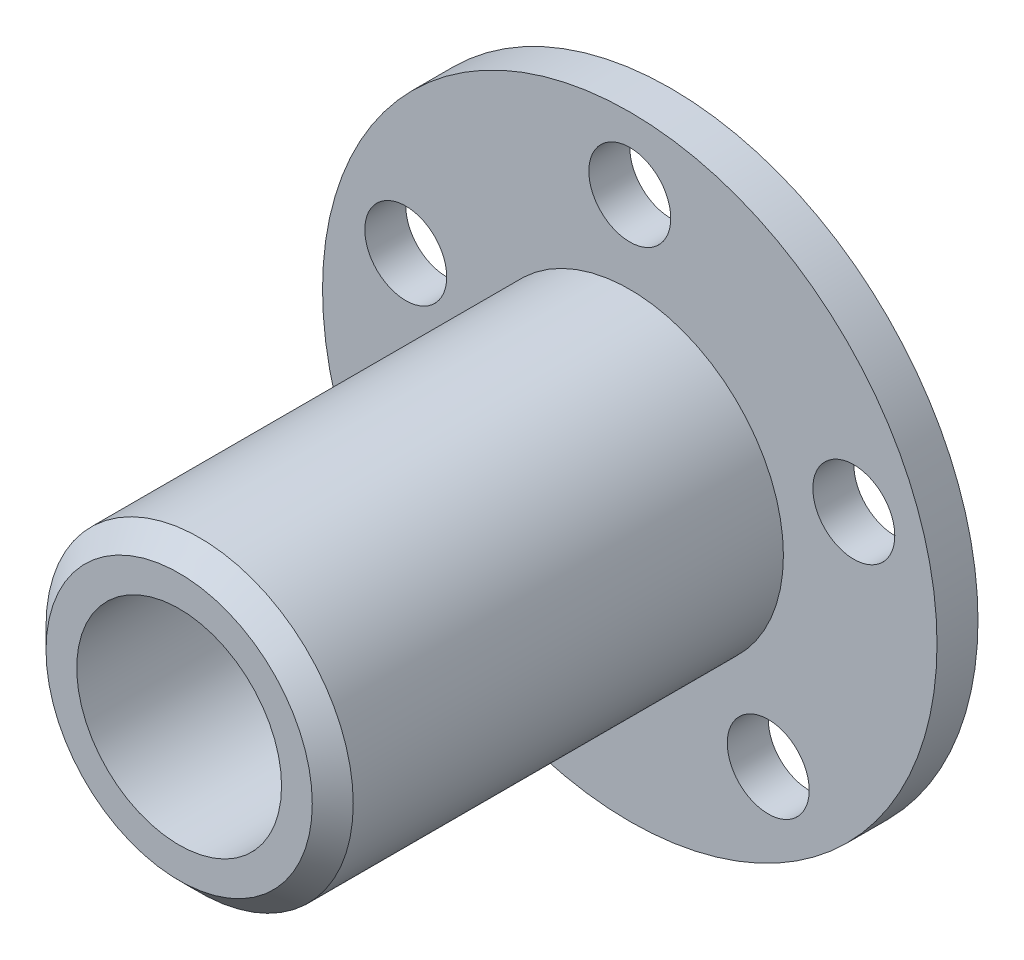
from build123d import *

# Parameters (mm, degrees)
SKETCH1_R           = 15
BOSS_EXTRUDE1_DEPTH = 2
SKETCH2_R           = 7.5
BOSS_EXTRUDE2_DEPTH = 22
SKETCH3_R           = 5
CUT_EXTRUDE1_DEPTH  = 25
SKETCH4_R           = 2
CUT_EXTRUDE2_DEPTH  = 3
CHAMFER1_SIZE       = 1
CHAMFER2_SIZE       = 1


with BuildPart() as part:
    # Sketch1 → Boss-Extrude1 (new body)
    with BuildSketch(Plane.XY):
        Circle(SKETCH1_R)
    extrude(amount=BOSS_EXTRUDE1_DEPTH)

    # Sketch2 → Boss-Extrude2 (add)
    with BuildSketch(Plane.XY.offset(2)):
        Circle(SKETCH2_R)
    extrude(amount=BOSS_EXTRUDE2_DEPTH)

    # Sketch3 → Cut-Extrude1 (cut, through all)
    with BuildSketch(Plane.XY.offset(24)):
        Circle(SKETCH3_R)
    extrude(amount=-CUT_EXTRUDE1_DEPTH, mode=Mode.SUBTRACT)

    # Sketch4 → Cut-Extrude2 (cut, through all)
    with BuildSketch(Plane.XY.offset(2)):
        with Locations((0, 11.5)):
            Circle(SKETCH4_R)
        with Locations((10.937149937, 3.553695435)):
            Circle(SKETCH4_R)
        with Locations((6.759530401, -9.303695435)):
            Circle(SKETCH4_R)
        with Locations((-6.759530401, -9.303695435)):
            Circle(SKETCH4_R)
        with Locations((-10.937149937, 3.553695435)):
            Circle(SKETCH4_R)
    extrude(amount=-CUT_EXTRUDE2_DEPTH, mode=Mode.SUBTRACT)

    # Chamfer1
    chamfer1_edges = [part.edges().sort_by_distance(p)[0] for p in [
        (-5, 0, 0),
    ]]
    chamfer(chamfer1_edges, length=CHAMFER1_SIZE)

    # Chamfer2
    chamfer2_edges = [part.edges().sort_by_distance(p)[0] for p in [
        (-7.5, 0, 24),
    ]]
    chamfer(chamfer2_edges, length=CHAMFER2_SIZE)


solid = part.part
